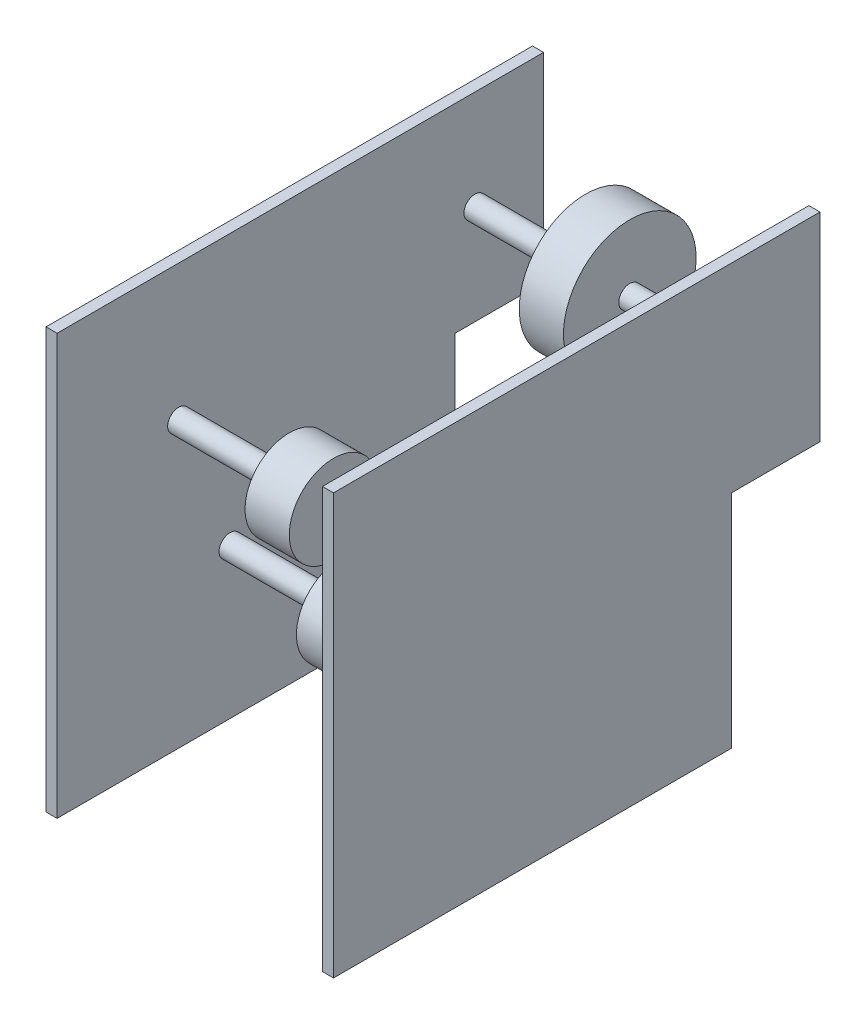
from build123d import *

# Parameters (mm, degrees)
BOSS_EXTRUDE1_DEPTH   = 82.55
SKETCH2_W             = 152.4
SKETCH2_H             = 279.4
CUT_EXTRUDE1_DEPTH    = 242.3
SKETCH3_R             = 25.4
BOSS_EXTRUDE2_DEPTH   = 12.7
SKETCH3_R_2           = 38.1
BOSS_EXTRUDE2_2_DEPTH = 12.7
BOSS_EXTRUDE2_3_DEPTH = 12.7
BOSS_EXTRUDE2_4_DEPTH = 12.7
SKETCH4_R             = 6.35
BOSS_EXTRUDE3_DEPTH   = 76.2


with BuildPart() as part:
    # Sketch1 → Boss-Extrude1 (new body, symmetric)
    with BuildSketch(Plane(origin=(0, 0, 0), x_dir=(0, 0, -1), z_dir=(1, 0, 0))):
        Polygon((0, 0), (228.6, 0), (228.6, 127), (279.4, 127), (279.4, 241.3), (0, 241.3), align=None)
    extrude(amount=BOSS_EXTRUDE1_DEPTH, both=True)

    # Sketch2 → Cut-Extrude1 (cut, through all)
    with BuildSketch(Plane(origin=(0, 241.3, 0), x_dir=(1, 0, 0), z_dir=(0, 1, 0))):
        with Locations((0, 139.7)):
            Rectangle(SKETCH2_W, SKETCH2_H)
    extrude(amount=-CUT_EXTRUDE1_DEPTH, mode=Mode.SUBTRACT)



with BuildPart() as body_2:
    # Sketch3 → Boss-Extrude2 (new body, symmetric)
    with BuildSketch(Plane(origin=(0, 0, 0), x_dir=(0, 0, -1), z_dir=(1, 0, 0))):
        with Locations((161.472166443, 31.75)):
            Circle(SKETCH3_R)
    extrude(amount=BOSS_EXTRUDE2_DEPTH, both=True)


with BuildPart() as body_3:
    # Sketch3 → Boss-Extrude2 2 (new body, symmetric)
    with BuildSketch(Plane(origin=(0, 0, 0), x_dir=(0, 0, -1), z_dir=(1, 0, 0))):
        with Locations((240.017328611, 184.15)):
            Circle(SKETCH3_R_2)
    extrude(amount=BOSS_EXTRUDE2_2_DEPTH, both=True)


with BuildPart() as body_4:
    # Sketch3 → Boss-Extrude2 3 (new body, symmetric)
    with BuildSketch(Plane(origin=(0, 0, 0), x_dir=(0, 0, -1), z_dir=(1, 0, 0))):
        with Locations((69.85, 163.217184297)):
            Circle(SKETCH3_R)
    extrude(amount=BOSS_EXTRUDE2_3_DEPTH, both=True)


with BuildPart() as body_5:
    # Sketch3 → Boss-Extrude2 4 (new body, symmetric)
    with BuildSketch(Plane(origin=(0, 0, 0), x_dir=(0, 0, -1), z_dir=(1, 0, 0))):
        with Locations((99.356812104, 86.120812531)):
            Circle(SKETCH3_R)
    extrude(amount=BOSS_EXTRUDE2_4_DEPTH, both=True)


with BuildPart() as part_1:
    add(part.part)

    add(body_2.part)  # Boss-Extrude3 merges body 2

    add(body_3.part)  # Boss-Extrude3 merges body 3

    add(body_4.part)  # Boss-Extrude3 merges body 4

    add(body_5.part)  # Boss-Extrude3 merges body 5
    # Sketch4 → Boss-Extrude3 (add, symmetric)
    with BuildSketch(Plane(origin=(0, 0, 0), x_dir=(0, 0, -1), z_dir=(1, 0, 0))):
        with Locations((69.85, 163.217184297)):
            Circle(SKETCH4_R)
        with Locations((99.356812104, 86.120812531)):
            Circle(SKETCH4_R)
        with Locations((161.472166443, 31.75)):
            Circle(SKETCH4_R)
        with Locations((240.017328611, 184.15)):
            Circle(SKETCH4_R)
    extrude(amount=BOSS_EXTRUDE3_DEPTH, both=True)


solid = part_1.part
